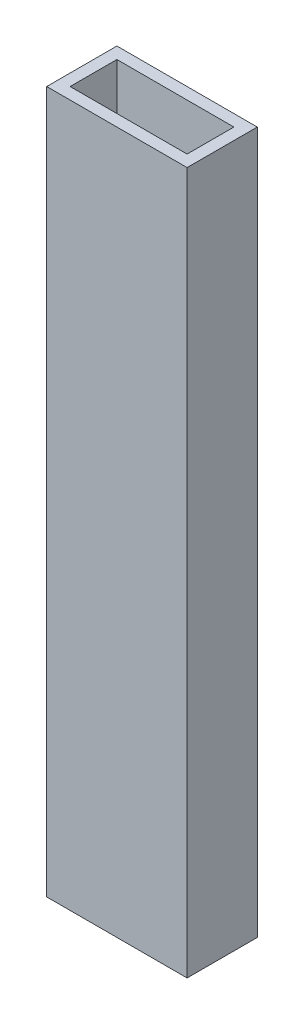
from build123d import *

# Parameters (mm, degrees)
SKETCH1_W           = 38.1
SKETCH1_H           = 19.05
SKETCH1_W_2         = 31.75
SKETCH1_H_2         = 12.7
BOSS_EXTRUDE1_DEPTH = 190.5


with BuildPart() as part:
    # Sketch1 → Boss-Extrude1 (new body)
    with BuildSketch(Plane(origin=(0, 0, 0), x_dir=(1, 0, 0), z_dir=(0, 1, 0))):
        with Locations((19.05, 9.525)):
            Rectangle(SKETCH1_W, SKETCH1_H)
        with Locations((19.05, 9.525)):
            Rectangle(SKETCH1_W_2, SKETCH1_H_2, mode=Mode.SUBTRACT)
    extrude(amount=BOSS_EXTRUDE1_DEPTH)


solid = part.part
